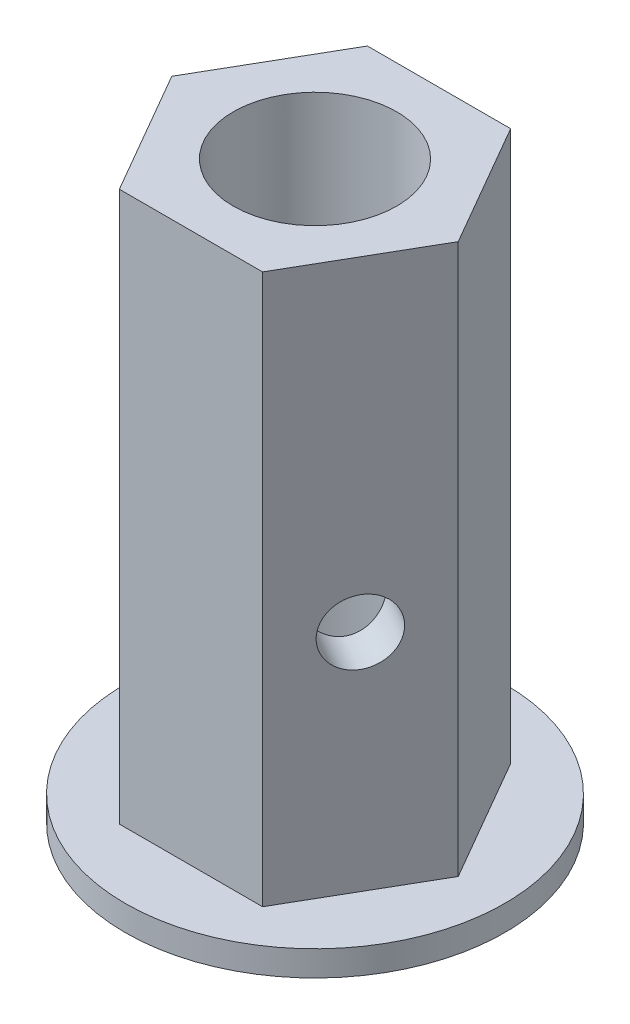
from build123d import *

# Parameters (mm, degrees)
BOSS_EXTRUDE1_DEPTH = 27.5844
SKETCH3_R           = 1.6256
CUT_EXTRUDE2_DEPTH  = 16.5575
SKETCH4_R           = 9.525
BOSS_EXTRUDE3_DEPTH = 1.27
SKETCH2_R           = 4.1021
CUT_EXTRUDE1_DEPTH  = 29.8544


with BuildPart() as part:
    # Sketch1 → Boss-Extrude1 (new body)
    with BuildSketch(Plane(origin=(0, 0, 0), x_dir=(1, 0, 0), z_dir=(0, 1, 0))):
        Polygon((-3.592850725, 6.223), (-7.18570145, 0), (-3.592850725, -6.223), (3.592850725, -6.223), (7.18570145, 0), (3.592850725, 6.223), align=None)
    extrude(amount=BOSS_EXTRUDE1_DEPTH)

    # Sketch3 → Cut-Extrude2 (cut, through all)
    with BuildSketch(Plane(origin=(5.389276088, 0, 3.1115), x_dir=(0.5, 0, -0.866025404), z_dir=(0.866025404, 0, 0.5))):
        with Locations((0, 11.2776)):
            Circle(SKETCH3_R)
    extrude(amount=-CUT_EXTRUDE2_DEPTH, mode=Mode.SUBTRACT)

    # Sketch4 → Boss-Extrude3 (add)
    with BuildSketch(Plane.XZ):
        Circle(SKETCH4_R)
    extrude(amount=BOSS_EXTRUDE3_DEPTH)

    # Sketch2 → Cut-Extrude1 (cut, through all)
    with BuildSketch(Plane(origin=(0, 27.5844, 0), x_dir=(1, 0, 0), z_dir=(0, 1, 0))):
        Circle(SKETCH2_R)
    extrude(amount=-CUT_EXTRUDE1_DEPTH, mode=Mode.SUBTRACT)


solid = part.part
